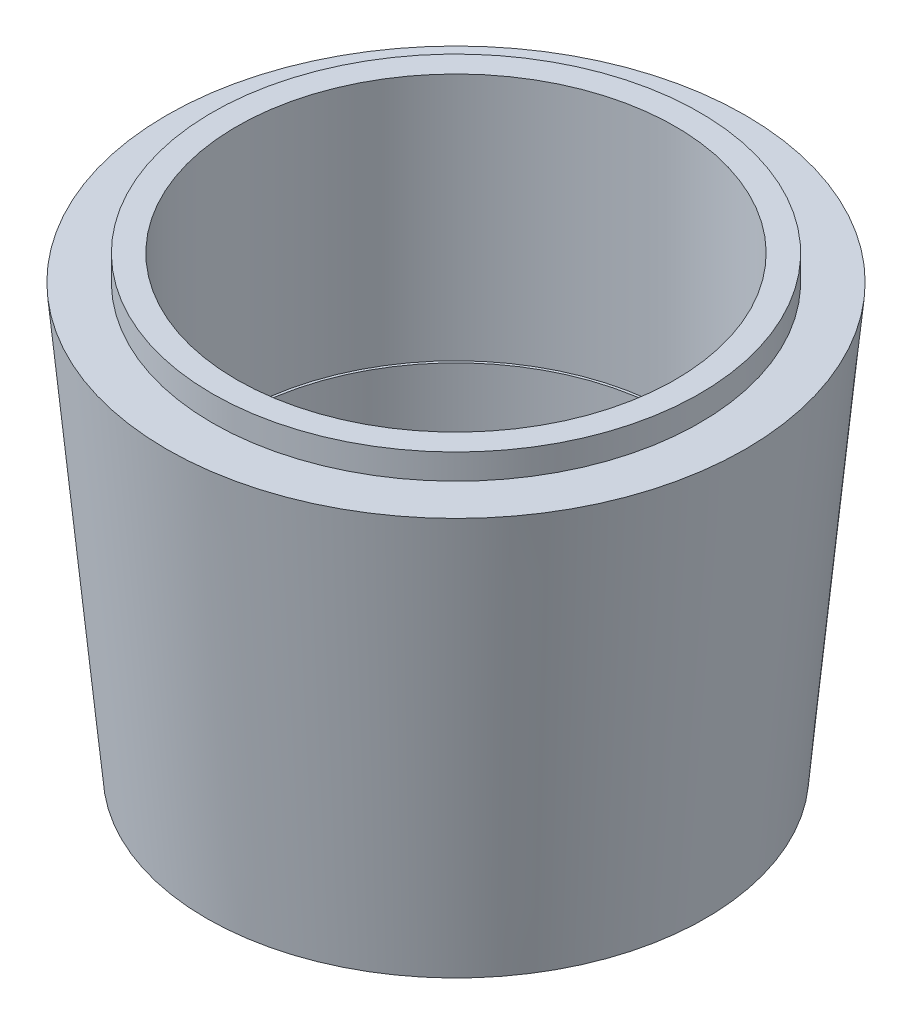
from build123d import *


with BuildPart() as part:
    # Sketch1 → Revolve1 (revolve)
    with BuildSketch(Plane.XY):
        Polygon((20.066, -32.512), (22.544576626, -42.836014649), (25.084576626, -42.836014649), (29.083, 0), (24.4983, 0), (24.4983, 2.54), (22.0472, 2.54), (22.0472, -22.4282), (21.7932, -22.4282), (21.7932, -32.512), align=None)
    revolve(axis=Axis((0, 5.641532331, 0), (0, -1, 0)))


solid = part.part
